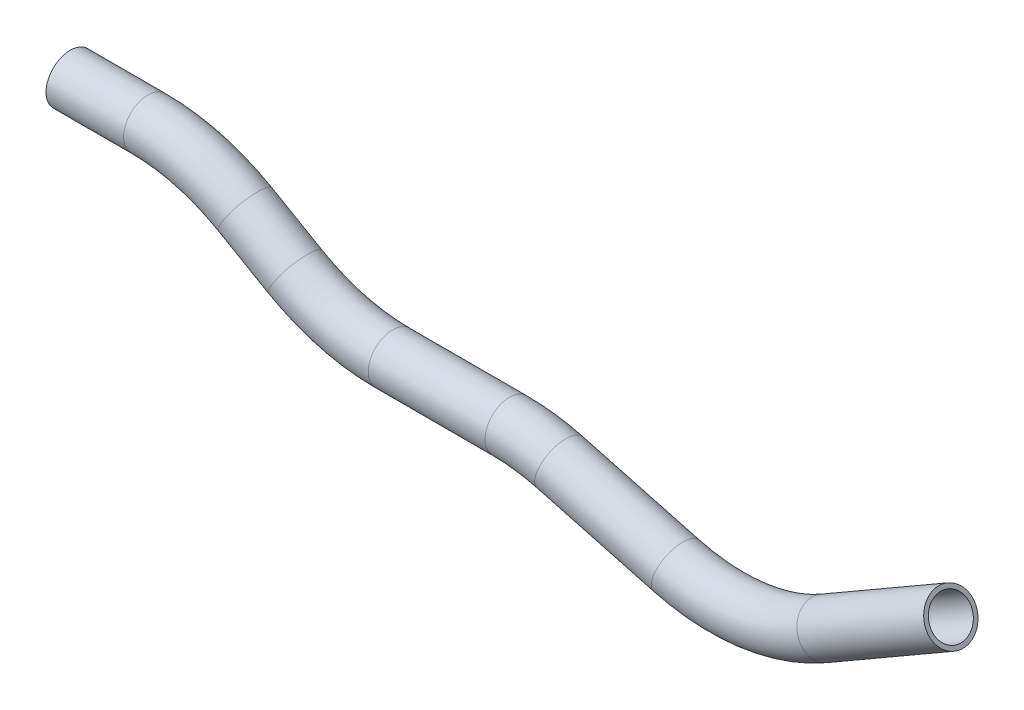
from build123d import *

# Parameters (mm, degrees)
SKETCH2_R   = 9.525
SKETCH2_R_2 = 7.874


with BuildPart() as part:
    # Sweep1: sweep along a path in Sketch1
    with BuildLine(Plane.XY) as sweep1_path:
        Line((-53.314642444, 60.835625073), (-22.932370908, 60.835625073))
        ThreePointArc((-22.932370908, 60.835625073), (-3.210359671, 58.239173036), (15.167629092, 50.626760841))
        Line((15.167629092, 50.626760841), (34.795699159, 39.294489304))
        ThreePointArc((34.795699159, 39.294489304), (53.173687922, 31.682077109), (72.895699159, 29.085625073))
        Line((72.895699159, 29.085625073), (118.64605038, 29.085625073))
        ThreePointArc((118.64605038, 29.085625073), (128.592146227, 28.433723509), (138.368061617, 26.489173036))
        Line((138.368061617, 26.489173036), (184.061188848, 14.245736494))
        ThreePointArc((184.061188848, 14.245736494), (213.729295932, 12.301186021), (241.883200085, 21.858148689))
        Line((241.883200085, 21.858148689), (291.53843505, 50.526611963))
    # Sketch2 → Sweep1 (sweep)
    with BuildSketch(Plane(origin=(-53.314642444, 60.835625073, 0), x_dir=(0, 0, -1), z_dir=(1, 0, 0))):
        Circle(SKETCH2_R)
        Circle(SKETCH2_R_2, mode=Mode.SUBTRACT)
    sweep(path=sweep1_path.line)


solid = part.part
